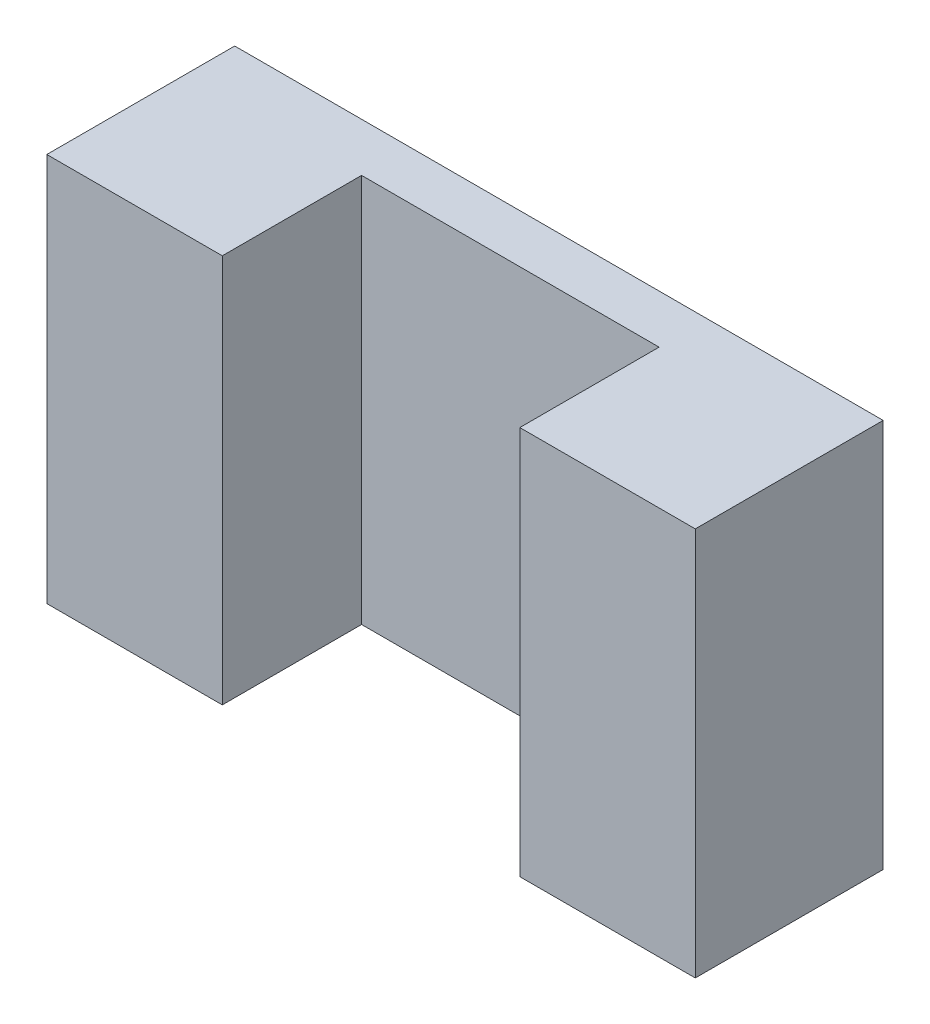
from build123d import *

# Parameters (mm, degrees)
SKETCH1_W           = 66.43745389
SKETCH1_H           = 39.85
BOSS_EXTRUDE1_DEPTH = 20
SKETCH2_W           = 30.48
SKETCH2_H           = 39.85
CUT_EXTRUDE1_DEPTH  = 15.02
SKETCH3_W           = 66.43745389
SKETCH3_H           = 39.85
CUT_EXTRUDE2_DEPTH  = 0.75


with BuildPart() as part:
    # Sketch1 → Boss-Extrude1 (new body)
    with BuildSketch(Plane.XY):
        Rectangle(SKETCH1_W, SKETCH1_H)
    extrude(amount=BOSS_EXTRUDE1_DEPTH)

    # Sketch2 → Cut-Extrude1 (cut)
    with BuildSketch(Plane.XY.offset(20)):
        Rectangle(SKETCH2_W, SKETCH2_H)
    extrude(amount=-CUT_EXTRUDE1_DEPTH, mode=Mode.SUBTRACT)

    # Sketch3 → Cut-Extrude2 (cut)
    with BuildSketch(Plane.XY.offset(20)):
        Rectangle(SKETCH3_W, SKETCH3_H)
    extrude(amount=-CUT_EXTRUDE2_DEPTH, mode=Mode.SUBTRACT)


solid = part.part
